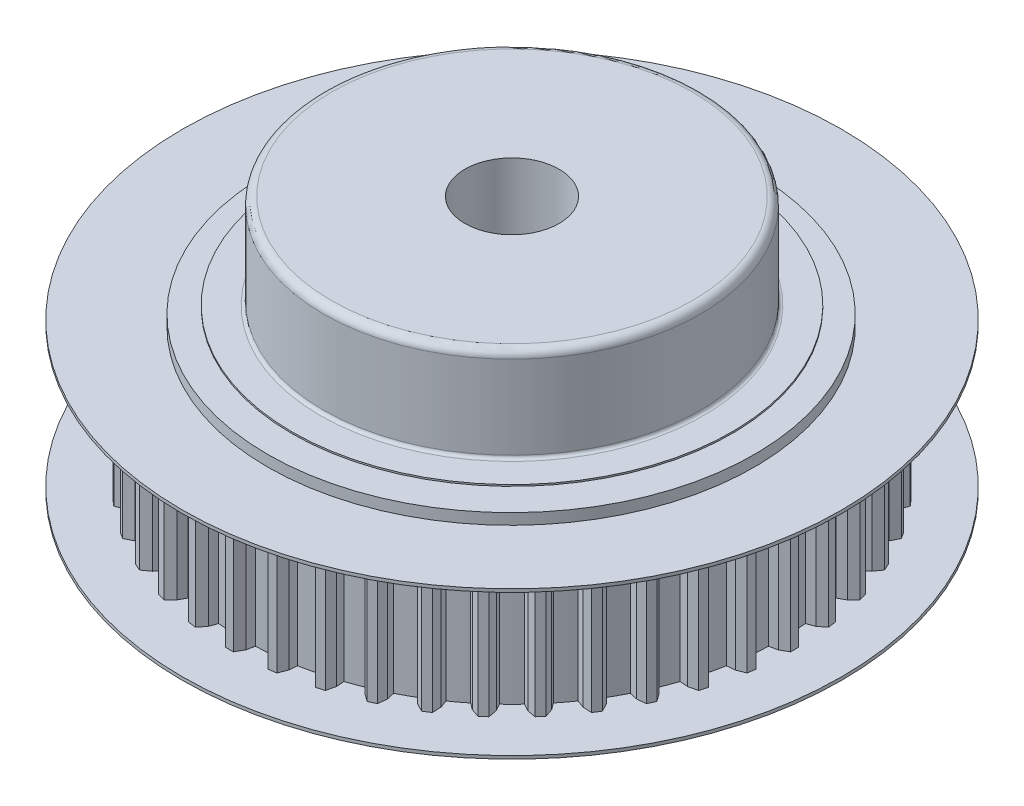
from build123d import *

# Parameters (mm, degrees)
ESQUISSE1_R             = 17
BOSS_EXTRU_1_DEPTH      = 9
BOSS_EXTRU_3_DEPTH      = 9
ESQUISSE3_R             = 21
BOSS_EXTRU_4_DEPTH      = 0.2
ESQUISSE4_R             = 15.5
BOSS_EXTRU_5_DEPTH      = 0.7
ESQUISSE5_R             = 14
BOSS_EXTRU_6_DEPTH      = 0.1
ESQUISSE6_R             = 21
BOSS_EXTRU_7_DEPTH      = 0.2
ESQUISSE7_R             = 15.5
BOSS_EXTRU_8_DEPTH      = 0.7
ESQUISSE8_R             = 14
BOSS_EXTRU_9_DEPTH      = 0.1
ESQUISSE9_R             = 12
BOSS_EXTRU_10_DEPTH     = 6
CONG_1_R                = 0.5
CONG_2_R                = 0.2
ESQUISSE10_R            = 3
ENL_V_MAT_EXTRU_1_DEPTH = 18


with BuildPart() as part:
    # Esquisse1 → Boss.-Extru.1 (new body)
    with BuildSketch(Plane(origin=(0, 0, 0), x_dir=(1, 0, 0), z_dir=(0, 1, 0))):
        Circle(ESQUISSE1_R)
    extrude(amount=BOSS_EXTRU_1_DEPTH)

    # Esquisse2 → Boss.-Extru.3 (add)
    with BuildSketch(Plane(origin=(0, 9, 0), x_dir=(1, 0, 0), z_dir=(0, 1, 0))):
        Polygon((-0.25, 18), (0.25, 18), (0.538675135, 17.5), (0.65, 16.987568984), (-0.65, 16.987568984), (-0.543549914, 17.491556634), align=None)
        Polygon((2.314211728, 17.852364663), (2.809122449, 17.781207244), (3.023701868, 17.245213768), (3.06096707, 16.722155381), (1.774199195, 16.907164671), (1.951290694, 17.390873027), align=None)
        Polygon((4.83131278, 17.341306664), (5.311059267, 17.200440386), (5.447174751, 16.639364715), (5.409621677, 16.116326917), (4.162280812, 16.482579241), (4.40640865, 16.936161395), align=None)
        Polygon((7.250062235, 16.47722967), (7.704878233, 16.269522163), (7.759758865, 15.694786181), (7.648151988, 15.182416513), (6.465630394, 15.72245603), (6.771824834, 16.136678358), align=None)
        Polygon((9.521221331, 15.277723795), (9.941848097, 15.007403387), (9.914376665, 14.430707059), (9.730987979, 13.939435891), (8.637358386, 14.642268954), (8.999386192, 15.008699083), align=None)
        Polygon((11.598555817, 13.767207522), (11.976430605, 13.439777155), (11.867166348, 12.872860357), (11.615729116, 12.412688552), (10.63325467, 13.264007506), (11.043745999, 13.575185977), align=None)
        Polygon((13.439777155, 11.976430605), (13.767207522, 11.598555817), (13.578374745, 11.05295934), (13.264007506, 10.63325467), (12.412688552, 11.615729116), (12.863286986, 11.865321232), align=None)
        Polygon((15.007403387, 9.941848097), (15.277723795, 9.521221331), (15.01316659, 9.008051945), (14.642268954, 8.637358386), (13.939435891, 9.730987979), (14.420968543, 9.913912763), align=None)
        Polygon((16.269522163, 7.704878233), (16.47722967, 7.250062235), (16.142333657, 6.77976659), (15.72245603, 6.465630394), (15.182416513, 7.648151988), (15.685080769, 7.76068562), align=None)
        Polygon((17.200440386, 5.311059267), (17.341306664, 4.83131278), (16.942889361, 4.413464738), (16.482579241, 4.162280812), (16.116326917, 5.409621677), (16.629889981, 5.449473297), align=None)
        Polygon((17.781207244, 2.809122449), (17.852364663, 2.314211728), (17.398536698, 1.957317471), (16.907164671, 1.774199195), (16.722155381, 3.06096707), (17.23616259, 3.027325413), align=None)
        Polygon((18, 0.25), (18, -0.25), (17.5, -0.538675135), (16.987568984, -0.65), (16.987568984, 0.65), (17.491556634, 0.543549914), align=None)
        Polygon((17.852364663, -2.314211728), (17.781207244, -2.809122449), (17.245213768, -3.023701868), (16.722155381, -3.06096707), (16.907164671, -1.774199195), (17.390873027, -1.951290694), align=None)
        Polygon((17.341306664, -4.83131278), (17.200440386, -5.311059267), (16.639364715, -5.447174751), (16.116326917, -5.409621677), (16.482579241, -4.162280812), (16.936161395, -4.40640865), align=None)
        Polygon((16.47722967, -7.250062235), (16.269522163, -7.704878233), (15.694786181, -7.759758865), (15.182416513, -7.648151988), (15.72245603, -6.465630394), (16.136678358, -6.771824834), align=None)
        Polygon((15.277723795, -9.521221331), (15.007403387, -9.941848097), (14.430707059, -9.914376665), (13.939435891, -9.730987979), (14.642268954, -8.637358386), (15.008699083, -8.999386192), align=None)
        Polygon((13.767207522, -11.598555817), (13.439777155, -11.976430605), (12.872860357, -11.867166348), (12.412688552, -11.615729116), (13.264007506, -10.63325467), (13.575185977, -11.043745999), align=None)
        Polygon((11.976430605, -13.439777155), (11.598555817, -13.767207522), (11.05295934, -13.578374745), (10.63325467, -13.264007506), (11.615729116, -12.412688552), (11.865321232, -12.863286986), align=None)
        Polygon((9.941848097, -15.007403387), (9.521221331, -15.277723795), (9.008051945, -15.01316659), (8.637358386, -14.642268954), (9.730987979, -13.939435891), (9.913912763, -14.420968543), align=None)
        Polygon((7.704878233, -16.269522163), (7.250062235, -16.47722967), (6.77976659, -16.142333657), (6.465630394, -15.72245603), (7.648151988, -15.182416513), (7.76068562, -15.685080769), align=None)
        Polygon((5.311059267, -17.200440386), (4.83131278, -17.341306664), (4.413464738, -16.942889361), (4.162280812, -16.482579241), (5.409621677, -16.116326917), (5.449473297, -16.629889981), align=None)
        Polygon((2.809122449, -17.781207244), (2.314211728, -17.852364663), (1.957317471, -17.398536698), (1.774199195, -16.907164671), (3.06096707, -16.722155381), (3.027325413, -17.23616259), align=None)
        Polygon((0.25, -18), (-0.25, -18), (-0.538675135, -17.5), (-0.65, -16.987568984), (0.65, -16.987568984), (0.543549914, -17.491556634), align=None)
        Polygon((-2.314211728, -17.852364663), (-2.809122449, -17.781207244), (-3.023701868, -17.245213768), (-3.06096707, -16.722155381), (-1.774199195, -16.907164671), (-1.951290694, -17.390873027), align=None)
        Polygon((-4.83131278, -17.341306664), (-5.311059267, -17.200440386), (-5.447174751, -16.639364715), (-5.409621677, -16.116326917), (-4.162280812, -16.482579241), (-4.40640865, -16.936161395), align=None)
        Polygon((-7.250062235, -16.47722967), (-7.704878233, -16.269522163), (-7.759758865, -15.694786181), (-7.648151988, -15.182416513), (-6.465630394, -15.72245603), (-6.771824834, -16.136678358), align=None)
        Polygon((-9.521221331, -15.277723795), (-9.941848097, -15.007403387), (-9.914376665, -14.430707059), (-9.730987979, -13.939435891), (-8.637358386, -14.642268954), (-8.999386192, -15.008699083), align=None)
        Polygon((-11.598555817, -13.767207522), (-11.976430605, -13.439777155), (-11.867166348, -12.872860357), (-11.615729116, -12.412688552), (-10.63325467, -13.264007506), (-11.043745999, -13.575185977), align=None)
        Polygon((-13.439777155, -11.976430605), (-13.767207522, -11.598555817), (-13.578374745, -11.05295934), (-13.264007506, -10.63325467), (-12.412688552, -11.615729116), (-12.863286986, -11.865321232), align=None)
        Polygon((-15.007403387, -9.941848097), (-15.277723795, -9.521221331), (-15.01316659, -9.008051945), (-14.642268954, -8.637358386), (-13.939435891, -9.730987979), (-14.420968543, -9.913912763), align=None)
        Polygon((-16.269522163, -7.704878233), (-16.47722967, -7.250062235), (-16.142333657, -6.77976659), (-15.72245603, -6.465630394), (-15.182416513, -7.648151988), (-15.685080769, -7.76068562), align=None)
        Polygon((-17.200440386, -5.311059267), (-17.341306664, -4.83131278), (-16.942889361, -4.413464738), (-16.482579241, -4.162280812), (-16.116326917, -5.409621677), (-16.629889981, -5.449473297), align=None)
        Polygon((-17.781207244, -2.809122449), (-17.852364663, -2.314211728), (-17.398536698, -1.957317471), (-16.907164671, -1.774199195), (-16.722155381, -3.06096707), (-17.23616259, -3.027325413), align=None)
        Polygon((-18, -0.25), (-18, 0.25), (-17.5, 0.538675135), (-16.987568984, 0.65), (-16.987568984, -0.65), (-17.491556634, -0.543549914), align=None)
        Polygon((-17.852364663, 2.314211728), (-17.781207244, 2.809122449), (-17.245213768, 3.023701868), (-16.722155381, 3.06096707), (-16.907164671, 1.774199195), (-17.390873027, 1.951290694), align=None)
        Polygon((-17.341306664, 4.83131278), (-17.200440386, 5.311059267), (-16.639364715, 5.447174751), (-16.116326917, 5.409621677), (-16.482579241, 4.162280812), (-16.936161395, 4.40640865), align=None)
        Polygon((-16.47722967, 7.250062235), (-16.269522163, 7.704878233), (-15.694786181, 7.759758865), (-15.182416513, 7.648151988), (-15.72245603, 6.465630394), (-16.136678358, 6.771824834), align=None)
        Polygon((-15.277723795, 9.521221331), (-15.007403387, 9.941848097), (-14.430707059, 9.914376665), (-13.939435891, 9.730987979), (-14.642268954, 8.637358386), (-15.008699083, 8.999386192), align=None)
        Polygon((-13.767207522, 11.598555817), (-13.439777155, 11.976430605), (-12.872860357, 11.867166348), (-12.412688552, 11.615729116), (-13.264007506, 10.63325467), (-13.575185977, 11.043745999), align=None)
        Polygon((-11.976430605, 13.439777155), (-11.598555817, 13.767207522), (-11.05295934, 13.578374745), (-10.63325467, 13.264007506), (-11.615729116, 12.412688552), (-11.865321232, 12.863286986), align=None)
        Polygon((-9.941848097, 15.007403387), (-9.521221331, 15.277723795), (-9.008051945, 15.01316659), (-8.637358386, 14.642268954), (-9.730987979, 13.939435891), (-9.913912763, 14.420968543), align=None)
        Polygon((-7.704878233, 16.269522163), (-7.250062235, 16.47722967), (-6.77976659, 16.142333657), (-6.465630394, 15.72245603), (-7.648151988, 15.182416513), (-7.76068562, 15.685080769), align=None)
        Polygon((-5.311059267, 17.200440386), (-4.83131278, 17.341306664), (-4.413464738, 16.942889361), (-4.162280812, 16.482579241), (-5.409621677, 16.116326917), (-5.449473297, 16.629889981), align=None)
        Polygon((-2.809122449, 17.781207244), (-2.314211728, 17.852364663), (-1.957317471, 17.398536698), (-1.774199195, 16.907164671), (-3.06096707, 16.722155381), (-3.027325413, 17.23616259), align=None)
    extrude(amount=-BOSS_EXTRU_3_DEPTH)

    # Esquisse3 → Boss.-Extru.4 (add)
    with BuildSketch(Plane(origin=(0, 9, 0), x_dir=(1, 0, 0), z_dir=(0, 1, 0))):
        Circle(ESQUISSE3_R)
    extrude(amount=BOSS_EXTRU_4_DEPTH)

    # Esquisse4 → Boss.-Extru.5 (add)
    with BuildSketch(Plane(origin=(0, 9.2, 0), x_dir=(1, 0, 0), z_dir=(0, 1, 0))):
        with Locations((0.35767124, -0.41735064)):
            Circle(ESQUISSE4_R)
    extrude(amount=BOSS_EXTRU_5_DEPTH)

    # Esquisse5 → Boss.-Extru.6 (add)
    with BuildSketch(Plane(origin=(0, 9.9, 0), x_dir=(1, 0, 0), z_dir=(0, 1, 0))):
        Circle(ESQUISSE5_R)
    extrude(amount=BOSS_EXTRU_6_DEPTH)

    # Esquisse6 → Boss.-Extru.7 (add)
    with BuildSketch(Plane.XZ):
        Circle(ESQUISSE6_R)
    extrude(amount=BOSS_EXTRU_7_DEPTH)

    # Esquisse7 → Boss.-Extru.8 (add)
    with BuildSketch(Plane(origin=(0, -0.2, 0), x_dir=(-1, 0, 0), z_dir=(0, -1, 0))):
        Circle(ESQUISSE7_R)
    extrude(amount=BOSS_EXTRU_8_DEPTH)

    # Esquisse8 → Boss.-Extru.9 (add)
    with BuildSketch(Plane(origin=(0, -0.9, 0), x_dir=(-1, 0, 0), z_dir=(0, -1, 0))):
        Circle(ESQUISSE8_R)
    extrude(amount=BOSS_EXTRU_9_DEPTH)

    # Esquisse9 → Boss.-Extru.10 (add)
    with BuildSketch(Plane(origin=(0, 10, 0), x_dir=(1, 0, 0), z_dir=(0, 1, 0))):
        Circle(ESQUISSE9_R)
    extrude(amount=BOSS_EXTRU_10_DEPTH)

    # Congé1
    cong_1_edges = [part.edges().sort_by_distance(p)[0] for p in [
        (-12, 16, 0),
    ]]
    fillet(cong_1_edges, radius=CONG_1_R)

    # Congé2
    cong_2_edges = [part.edges().sort_by_distance(p)[0] for p in [
        (-12, 10, 0),
    ]]
    fillet(cong_2_edges, radius=CONG_2_R)

    # Esquisse10 → Enlèv. mat.-Extru.1 (cut, through all)
    with BuildSketch(Plane(origin=(0, 16, 0), x_dir=(1, 0, 0), z_dir=(0, 1, 0))):
        Circle(ESQUISSE10_R)
    extrude(amount=-ENL_V_MAT_EXTRU_1_DEPTH, mode=Mode.SUBTRACT)


solid = part.part
